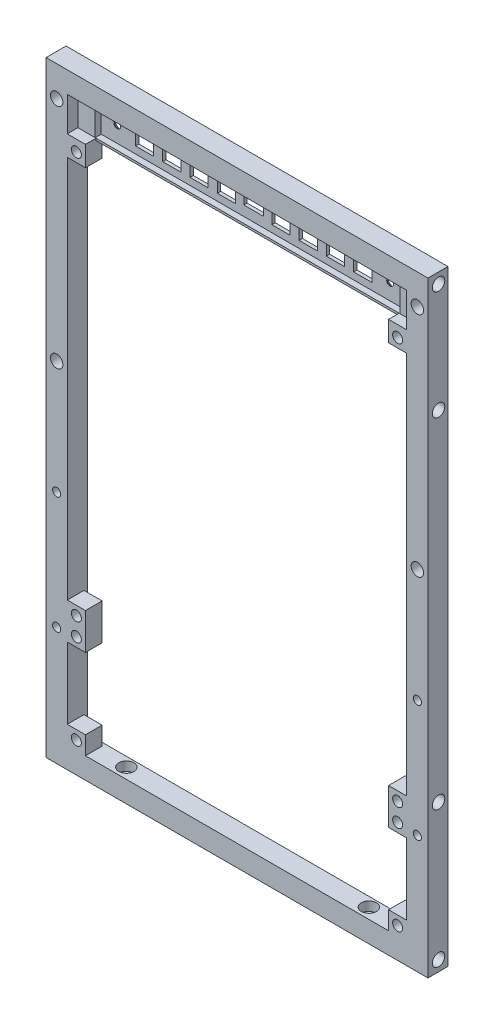
from build123d import *

# Parameters (mm, degrees)
SKETCH1_W                = 126
SKETCH1_H                = 200
SKETCH1_W_2              = 112
SKETCH1_H_2              = 186
BOSS_EXTRUDE1_DEPTH      = 7
SKETCH2_R                = 2.05
CUT_EXTRUDE1_DEPTH       = 6
SKETCH3_R                = 1.35
CUT_EXTRUDE2_DEPTH       = 204.142806912
SKETCH4_R                = 2.5
CUT_EXTRUDE3_DEPTH       = 3
SKETCH5_R                = 1.35
CUT_EXTRUDE4_DEPTH       = 119.397635112
SKETCH6_R                = 2.5
CUT_EXTRUDE5_DEPTH       = 3
SKETCH7_R                = 2.05
CUT_EXTRUDE6_DEPTH       = 119.397635112
CUT_EXTRUDE7_DEPTH       = 0.2
SKETCH9_W                = 2.7
SKETCH9_H                = 2.7
CUT_EXTRUDE8_DEPTH       = 0.2
SKETCH10_W               = 6
SKETCH10_H               = 6
BOSS_EXTRUDE2_DEPTH      = 5.5
SKETCH11_R               = 1.65
CUT_EXTRUDE9_DEPTH       = 119.318426291
SKETCH12_W               = 112
SKETCH12_H               = 12
BOSS_EXTRUDE3_DEPTH      = 1.5
SKETCH13_W               = 112
SKETCH13_H               = 12
SKETCH13_W_2             = 100.6
SKETCH13_H_2             = 10.6
BOSS_EXTRUDE4_DEPTH      = 2
SKETCH14_W               = 6
SKETCH14_H               = 6
SKETCH14_W_2             = 6.5
SKETCH14_H_2             = 4
CUT_EXTRUDE10_DEPTH      = 119.318426291
SKETCH15_R               = 1
BOSS_EXTRUDE5_DEPTH      = 2
CHAMFER1_SIZE            = 0.4
CHAMFER2_SIZE            = 0.4
CHAMFER3_SIZE            = 0.4
SKETCH16_W               = 6
SKETCH16_H               = 6
BOSS_EXTRUDE7_DEPTH      = 5.5
SKETCH17_R               = 1.65
CUT_EXTRUDE11_DEPTH      = 119.318426291
SKETCH18_R               = 1.1
CUT_EXTRUDE12_DEPTH      = 119.318426291
CUT_EXTRUDE12_DEPTH_BACK = 119.318426291
CHAMFER4_SIZE            = 1.3


with BuildPart() as part:
    # Sketch1 → Boss-Extrude1 (new body)
    with BuildSketch(Plane.XY):
        Rectangle(SKETCH1_W, SKETCH1_H)
        Rectangle(SKETCH1_W_2, SKETCH1_H_2, mode=Mode.SUBTRACT)
    extrude(amount=BOSS_EXTRUDE1_DEPTH)

    # Sketch2 → Cut-Extrude1 (cut)
    with BuildSketch(Plane.ZY.offset(63)):
        with Locations((3.5, -96.5)):
            Circle(SKETCH2_R)
        with Locations((3.5, 96.5)):
            Circle(SKETCH2_R)
        with Locations((3.5, 60.5)):
            Circle(SKETCH2_R)
        with Locations((3.5, -51.5)):
            Circle(SKETCH2_R)
    cut_extrude1 = extrude(amount=-CUT_EXTRUDE1_DEPTH, mode=Mode.SUBTRACT)

    # Mirror1: Cut-Extrude1 across plane
    add(cut_extrude1.mirror(Plane(origin=(0, 0, 0), x_dir=(0, 0, 1), z_dir=(1, 0, 0))), mode=Mode.SUBTRACT)

    # Sketch3 → Cut-Extrude2 (cut, through all)
    with BuildSketch(Plane(origin=(0, -93, 0), x_dir=(1, 0, 0), z_dir=(0, 1, 0))):
        with Locations(Location((40, -3.5, 0), (0, 0, 270))):
            Circle(SKETCH3_R)
        with Locations(Location((-40, -3.5, 0), (0, 0, 270))):
            Circle(SKETCH3_R)
    extrude(amount=-CUT_EXTRUDE2_DEPTH, mode=Mode.SUBTRACT)

    # Sketch4 → Cut-Extrude3 (cut)
    with BuildSketch(Plane(origin=(0, -93, 0), x_dir=(1, 0, 0), z_dir=(0, 1, 0))):
        with Locations(Location((40, -3.5, 0), (0, 0, 270))):
            Circle(SKETCH4_R)
        with Locations(Location((-40, -3.5, 0), (0, 0, 270))):
            Circle(SKETCH4_R)
    extrude(amount=-CUT_EXTRUDE3_DEPTH, mode=Mode.SUBTRACT)

    # Sketch5 → Cut-Extrude4 (cut, through all)
    with BuildSketch(Plane(origin=(0, 0, 0), x_dir=(-1, 0, 0), z_dir=(0, 0, -1))):
        with Locations((-59.5, -22.4)):
            Circle(SKETCH5_R)
        with Locations(Location((59.5, -22.4, 0), (0, 0, 180))):
            Circle(SKETCH5_R)
        with Locations((-59.5, -61)):
            Circle(SKETCH5_R)
        with Locations(Location((59.5, -61, 0), (0, 0, 180))):
            Circle(SKETCH5_R)
    extrude(amount=-CUT_EXTRUDE4_DEPTH, mode=Mode.SUBTRACT)

    # Sketch6 → Cut-Extrude5 (cut)
    with BuildSketch(Plane(origin=(0, 0, 0), x_dir=(-1, 0, 0), z_dir=(0, 0, -1))):
        with Locations((-59.5, -22.4)):
            Circle(SKETCH6_R)
        with Locations((59.5, -22.4)):
            Circle(SKETCH6_R)
        with Locations((-59.5, -61)):
            Circle(SKETCH6_R)
        with Locations((59.5, -61)):
            Circle(SKETCH6_R)
    extrude(amount=-CUT_EXTRUDE5_DEPTH, mode=Mode.SUBTRACT)

    # Sketch7 → Cut-Extrude6 (cut, through all)
    with BuildSketch(Plane(origin=(0, 0, 0), x_dir=(-1, 0, 0), z_dir=(0, 0, -1))):
        with Locations((-59.5, 90)):
            Circle(SKETCH7_R)
        with Locations((-59.5, 15)):
            Circle(SKETCH7_R)
    cut_extrude6 = extrude(amount=-CUT_EXTRUDE6_DEPTH, mode=Mode.SUBTRACT)

    # Mirror2: Cut-Extrude6 across plane
    add(cut_extrude6.mirror(Plane(origin=(0, 0, 0), x_dir=(0, 0, 1), z_dir=(1, 0, 0))), mode=Mode.SUBTRACT)

    # Sketch8 → Cut-Extrude7 (cut)
    with BuildSketch(Plane(origin=(0, 0, 3), x_dir=(-1, 0, 0), z_dir=(0, 0, -1))):
        with BuildLine():
            Line((-60.85, -24.504162541), (-60.85, -20.295837459))
            ThreePointArc((-60.85, -20.295837459), (-59.5, -19.9), (-58.15, -20.295837459))
            Line((-58.15, -20.295837459), (-58.15, -24.504162541))
            ThreePointArc((-58.15, -24.504162541), (-59.5, -24.9), (-60.85, -24.504162541))
        make_face()
        with BuildLine():
            Line((-60.85, -63.104162541), (-60.85, -58.895837459))
            ThreePointArc((-60.85, -58.895837459), (-59.5, -58.5), (-58.15, -58.895837459))
            Line((-58.15, -58.895837459), (-58.15, -63.104162541))
            ThreePointArc((-58.15, -63.104162541), (-59.5, -63.5), (-60.85, -63.104162541))
        make_face()
    cut_extrude7 = extrude(amount=-CUT_EXTRUDE7_DEPTH, mode=Mode.SUBTRACT)

    # Sketch9 → Cut-Extrude8 (cut)
    with BuildSketch(Plane(origin=(0, 0, 3.2), x_dir=(-1, 0, 0), z_dir=(0, 0, -1))):
        with Locations((-59.5, -22.4)):
            Rectangle(SKETCH9_W, SKETCH9_H)
        with Locations((-59.5, -61)):
            Rectangle(SKETCH9_W, SKETCH9_H)
    cut_extrude8 = extrude(amount=-CUT_EXTRUDE8_DEPTH, mode=Mode.SUBTRACT)

    # Mirror3: Cut-Extrude7, Cut-Extrude8 across plane
    add(cut_extrude7.mirror(Plane(origin=(0, 0, 0), x_dir=(0, 0, 1), z_dir=(1, 0, 0))), mode=Mode.SUBTRACT)
    add(cut_extrude8.mirror(Plane(origin=(0, 0, 0), x_dir=(0, 0, 1), z_dir=(1, 0, 0))), mode=Mode.SUBTRACT)

    # Sketch10 → Boss-Extrude2 (add)
    with BuildSketch(Plane.XY.offset(7)):
        with Locations((53, -90)):
            Rectangle(SKETCH10_W, SKETCH10_H)
        with Locations((53, -60.5)):
            Rectangle(SKETCH10_W, SKETCH10_H)
    boss_extrude2 = extrude(amount=-BOSS_EXTRUDE2_DEPTH)

    # Sketch11 → Cut-Extrude9 (cut, through all)
    with BuildSketch(Plane(origin=(0, 0, 1.5), x_dir=(-1, 0, 0), z_dir=(0, 0, -1))):
        with Locations((-53, -60.5)):
            Circle(SKETCH11_R)
        with Locations((-53, -90)):
            Circle(SKETCH11_R)
    cut_extrude9 = extrude(amount=-CUT_EXTRUDE9_DEPTH, mode=Mode.SUBTRACT)

    # Mirror4: Boss-Extrude2, Cut-Extrude9 across plane
    add(boss_extrude2.mirror(Plane(origin=(0, 0, 0), x_dir=(0, 0, 1), z_dir=(1, 0, 0))))
    add(cut_extrude9.mirror(Plane(origin=(0, 0, 0), x_dir=(0, 0, 1), z_dir=(1, 0, 0))), mode=Mode.SUBTRACT)

    # Sketch12 → Boss-Extrude3 (add)
    with BuildSketch(Plane(origin=(0, 0, 0), x_dir=(-1, 0, 0), z_dir=(0, 0, -1))):
        with Locations((0, 87)):
            Rectangle(SKETCH12_W, SKETCH12_H)
    extrude(amount=-BOSS_EXTRUDE3_DEPTH)

    # Sketch13 → Boss-Extrude4 (add)
    with BuildSketch(Plane.XY.offset(1.5)):
        with Locations((0, 87)):
            Rectangle(SKETCH13_W, SKETCH13_H)
        with Locations((0, 87)):
            Rectangle(SKETCH13_W_2, SKETCH13_H_2, mode=Mode.SUBTRACT)
    extrude(amount=BOSS_EXTRUDE4_DEPTH)

    # Sketch14 → Cut-Extrude10 (cut, through all)
    with BuildSketch(Plane.XY.offset(1.5)):
        with Locations((-36, 87)):
            Rectangle(SKETCH14_W, SKETCH14_H)
        with Locations((0, 87)):
            Rectangle(SKETCH14_W_2, SKETCH14_H_2)
        with Locations((9, 87)):
            Rectangle(SKETCH14_W, SKETCH14_H)
        with Locations((18, 87)):
            Rectangle(SKETCH14_W, SKETCH14_H)
        with Locations((27, 87)):
            Rectangle(SKETCH14_W, SKETCH14_H)
        with Locations((36, 87)):
            Rectangle(SKETCH14_W, SKETCH14_H)
        with Locations((-27, 87)):
            Rectangle(SKETCH14_W, SKETCH14_H)
        with Locations((-18, 87)):
            Rectangle(SKETCH14_W, SKETCH14_H)
        with Locations((-9, 87)):
            Rectangle(SKETCH14_W, SKETCH14_H)
    extrude(amount=-CUT_EXTRUDE10_DEPTH, mode=Mode.SUBTRACT)

    # Sketch15 → Boss-Extrude5 (add)
    with BuildSketch(Plane.XY.offset(1.5)):
        with Locations(Location((-45, 87, 0), (0, 0, 180))):
            Circle(SKETCH15_R)
        with Locations(Location((45, 87, 0), (0, 0, 180))):
            Circle(SKETCH15_R)
    extrude(amount=BOSS_EXTRUDE5_DEPTH)

    # Chamfer1
    chamfer1_edges = [part.edges().sort_by_distance(p)[0] for p in [
        (56, -6, 0),
        (0, -93, 0),
        (-56, -6, 0),
        (0, 81, 0),
    ]]
    chamfer(chamfer1_edges, length=CHAMFER1_SIZE)

    # Chamfer2
    chamfer2_edges = [part.edges().sort_by_distance(p)[0] for p in [
        (0, -100, 0),
        (-63, 0, 0),
        (0, 100, 0),
        (63, 0, 0),
    ]]
    chamfer(chamfer2_edges, length=CHAMFER2_SIZE)

    # Chamfer3
    chamfer3_edges = [part.edges().sort_by_distance(p)[0] for p in [
        (-6, 87, 0),
        (-9, 84, 0),
        (-12, 87, 0),
        (-9, 90, 0),
        (-15, 87, 0),
        (-18, 84, 0),
        (-21, 87, 0),
        (-18, 90, 0),
        (-24, 87, 0),
        (-27, 84, 0),
        (-30, 87, 0),
        (-27, 90, 0),
        (-33, 87, 0),
        (-36, 84, 0),
        (-39, 87, 0),
        (-36, 90, 0),
        (39, 87, 0),
        (36, 84, 0),
        (33, 87, 0),
        (36, 90, 0),
        (30, 87, 0),
        (27, 84, 0),
        (24, 87, 0),
        (27, 90, 0),
        (21, 87, 0),
        (18, 84, 0),
        (15, 87, 0),
        (18, 90, 0),
        (12, 87, 0),
        (9, 84, 0),
        (6, 87, 0),
        (9, 90, 0),
        (3.25, 87, 0),
        (0, 85, 0),
        (-3.25, 87, 0),
        (0, 89, 0),
    ]]
    chamfer(chamfer3_edges, length=CHAMFER3_SIZE)

    # Sketch16 → Boss-Extrude7 (add)
    with BuildSketch(Plane.XY.offset(7)):
        Polygon((-50, 81), (-50, 81.7), (-56, 81.7), (-56, 81), (-56, 75), (-50, 75), align=None)
        with Locations((-53, -54.5)):
            Rectangle(SKETCH16_W, SKETCH16_H)
        with Locations((53, -54.5)):
            Rectangle(SKETCH16_W, SKETCH16_H)
        Polygon((56, 81), (56, 75), (50, 75), (50, 81), (50, 81.7), (56, 81.7), align=None)
    extrude(amount=-BOSS_EXTRUDE7_DEPTH)

    # Sketch17 → Cut-Extrude11 (cut, through all)
    with BuildSketch(Plane(origin=(0, 0, 1.5), x_dir=(-1, 0, 0), z_dir=(0, 0, -1))):
        with Locations((-53, -54.5)):
            Circle(SKETCH17_R)
        with Locations((53, -54.5)):
            Circle(SKETCH17_R)
        with Locations((53, 78)):
            Circle(SKETCH17_R)
        with Locations((-53, 78)):
            Circle(SKETCH17_R)
    extrude(amount=-CUT_EXTRUDE11_DEPTH, mode=Mode.SUBTRACT)

    # Sketch18 → Cut-Extrude12 (cut, two sides)
    with BuildSketch(Plane.XY.offset(1.5)) as cut_extrude12_sk:
        with Locations((-45, 87)):
            Circle(SKETCH18_R)
        with Locations((45, 87)):
            Circle(SKETCH18_R)
    extrude(amount=CUT_EXTRUDE12_DEPTH, mode=Mode.SUBTRACT)
    extrude(cut_extrude12_sk.sketch, amount=-CUT_EXTRUDE12_DEPTH_BACK, mode=Mode.SUBTRACT)

    # Chamfer4
    chamfer4_edges = [part.edges().sort_by_distance(p)[0] for p in [
        (-46.1, 87, 0),
        (43.9, 87, 0),
    ]]
    chamfer(chamfer4_edges, length=CHAMFER4_SIZE)


solid = part.part
